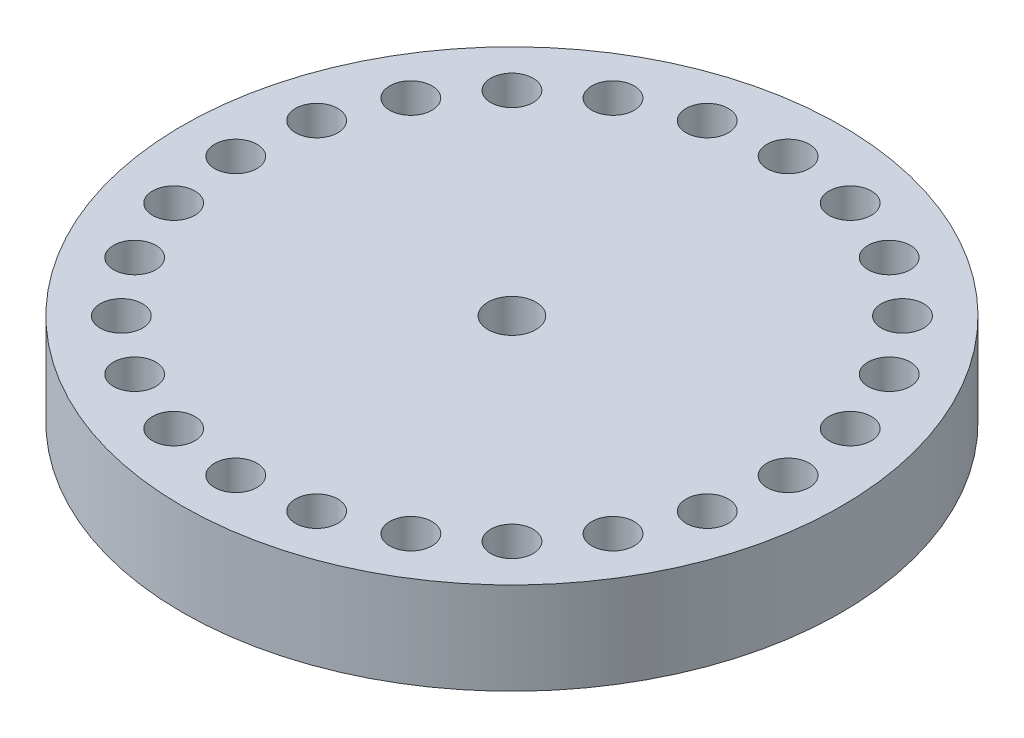
from build123d import *

# Parameters (mm, degrees)
SKETCH1_R                                        = 45.466
BOSS_EXTRUDE1_DEPTH                              = 25.4
CSK_FOR_1_4_FLAT_HEAD_MACHINE_SCREW1_D           = 6.5278
CSK_FOR_1_4_FLAT_HEAD_MACHINE_SCREW1_DEPTH       = 25.4
CSK_FOR_1_4_FLAT_HEAD_MACHINE_SCREW1_CSINK_D     = 12.8778
CSK_FOR_1_4_FLAT_HEAD_MACHINE_SCREW1_CSINK_ANGLE = 82
CSK_FOR_1_4_FLAT_HEAD_MACHINE_SCREW1_TIP         = 1.961148974
SKETCH8_R                                        = 46.955588052
CUT_EXTRUDE2_DEPTH                               = 12.7
SKETCH4_R                                        = 2.54
CUT_EXTRUDE3_DEPTH                               = 66.540859866
SKETCH9_R                                        = 2.921
CUT_EXTRUDE4_DEPTH                               = 5.08
SKETCH11_R                                       = 3.302
CUT_EXTRUDE5_DEPTH                               = 66.540859866
CIRPATTERN2_COUNT                                = 24
CIRPATTERN3_COUNT                                = 24


with BuildPart() as part:
    # Sketch1 → Boss-Extrude1 (new body)
    with BuildSketch(Plane(origin=(0, 0, 0), x_dir=(1, 0, 0), z_dir=(0, 1, 0))):
        Circle(SKETCH1_R)
    extrude(amount=BOSS_EXTRUDE1_DEPTH)

    # CSK for 1_4 Flat Head Machine Screw1
    with Locations(Plane(origin=(0, 25.4, 0), x_dir=(1, 0, 0), z_dir=(0, 1, 0))):
        with Locations((0, 0)):
            CounterSinkHole(CSK_FOR_1_4_FLAT_HEAD_MACHINE_SCREW1_D / 2, CSK_FOR_1_4_FLAT_HEAD_MACHINE_SCREW1_CSINK_D / 2, depth=CSK_FOR_1_4_FLAT_HEAD_MACHINE_SCREW1_DEPTH, counter_sink_angle=CSK_FOR_1_4_FLAT_HEAD_MACHINE_SCREW1_CSINK_ANGLE)
            with Locations((0, 0, -(CSK_FOR_1_4_FLAT_HEAD_MACHINE_SCREW1_DEPTH + CSK_FOR_1_4_FLAT_HEAD_MACHINE_SCREW1_TIP / 2))):  # 118° drill point
                Cone(0, CSK_FOR_1_4_FLAT_HEAD_MACHINE_SCREW1_D / 2, CSK_FOR_1_4_FLAT_HEAD_MACHINE_SCREW1_TIP, mode=Mode.SUBTRACT)

    # Sketch8 → Cut-Extrude2 (cut)
    with BuildSketch(Plane(origin=(0, 25.4, 0), x_dir=(1, 0, 0), z_dir=(0, 1, 0))):
        Circle(SKETCH8_R)
    extrude(amount=-CUT_EXTRUDE2_DEPTH, mode=Mode.SUBTRACT)

    # Sketch4 → Cut-Extrude3 (cut, through all)
    with BuildSketch(Plane.XZ):
        with Locations((0, 38.1)):
            Circle(SKETCH4_R)
    cut_extrude3 = extrude(amount=-CUT_EXTRUDE3_DEPTH, mode=Mode.SUBTRACT)

    # Sketch9 → Cut-Extrude4 (cut)
    with BuildSketch(Plane(origin=(0, 12.7, 0), x_dir=(1, 0, 0), z_dir=(0, 1, 0))):
        with Locations((0, -38.1)):
            Circle(SKETCH9_R)
    cut_extrude4 = extrude(amount=-CUT_EXTRUDE4_DEPTH, mode=Mode.SUBTRACT)

    # Sketch11 → Cut-Extrude5 (cut, through all)
    with BuildSketch(Plane(origin=(0, 12.7, 0), x_dir=(1, 0, 0), z_dir=(0, 1, 0))):
        Circle(SKETCH11_R)
    extrude(amount=-CUT_EXTRUDE5_DEPTH, mode=Mode.SUBTRACT)

    # CirPattern2: Cut-Extrude3 ×24 about axis
    cirpattern2_axis = Axis((0, 12.7, 0), (0, 1, 0))
    for i in range(1, CIRPATTERN2_COUNT):
        add(cut_extrude3.rotate(cirpattern2_axis, i * 360 / CIRPATTERN2_COUNT), mode=Mode.SUBTRACT)

    # CirPattern3: Cut-Extrude4 ×24 about axis
    cirpattern3_axis = Axis((0, 12.7, 0), (0, 1, 0))
    for i in range(1, CIRPATTERN3_COUNT):
        add(cut_extrude4.rotate(cirpattern3_axis, i * 360 / CIRPATTERN3_COUNT), mode=Mode.SUBTRACT)

    # Sketch13 → Revolve1 (revolve)
    with BuildSketch(Plane.YZ):
        with BuildLine():
            Line((0, 0), (-14.179303561, 0))
            ThreePointArc((-14.179303561, 0), (-14.007568062, 1.162621435), (-13.472719499, 2.209100627))
            Line((-13.472719499, 2.209100627), (0, 19.05))
            Line((0, 19.05), (0, 0))
        make_face()
    revolve(axis=Axis((0, 0, 0), (0, -1, 0)))


solid = part.part
